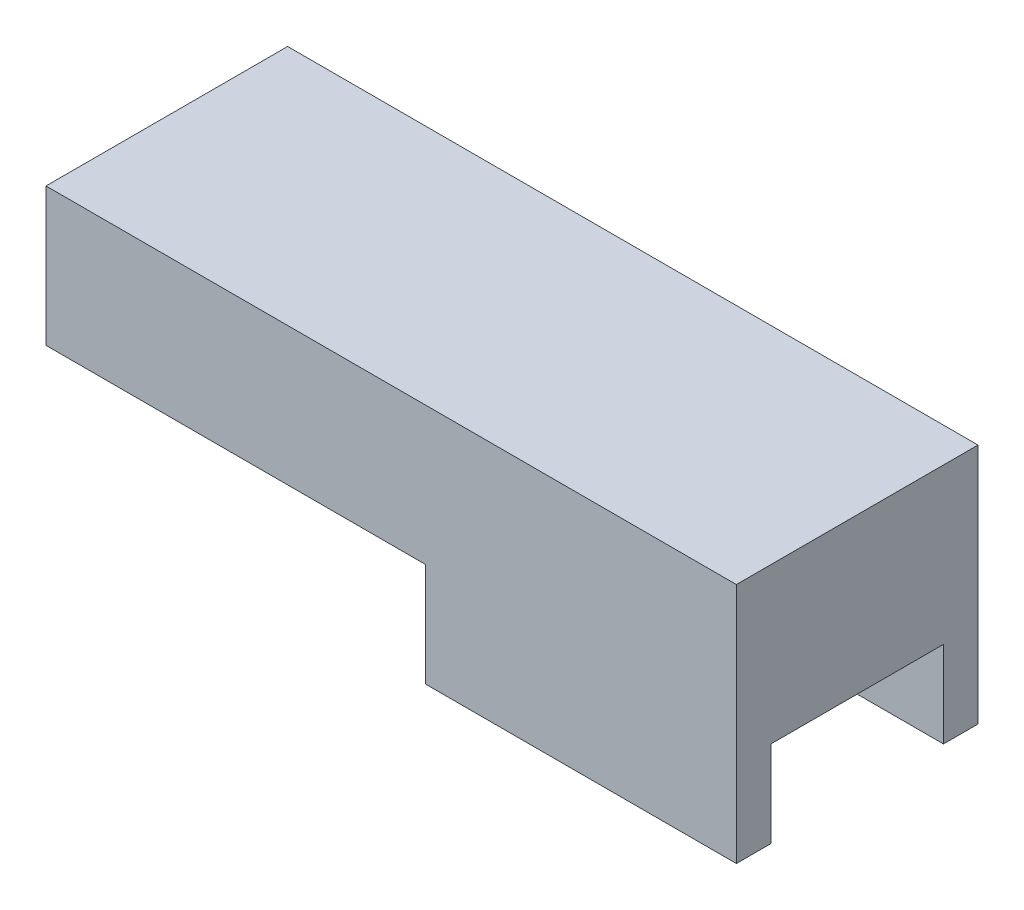
from build123d import *

# Parameters (mm, degrees)
EXTRUDE_2_DEPTH     = 70
SKETCH_3_W          = 50
SKETCH_3_H          = 25
CUT_EXTRUDE_3_DEPTH = 91


with BuildPart() as part:
    # 草图1 → 凸台-拉伸2 (new body)
    with BuildSketch(Plane.XY):
        Polygon((-42.561983471, 30.9508549), (157.438016529, 30.9508549), (157.438016529, -39.0491451), (67.438016529, -39.0491451), (67.438016529, -9.0491451), (-42.561983471, -9.0491451), align=None)
    extrude(amount=EXTRUDE_2_DEPTH)

    # 草图3 → 切除-拉伸3 (cut, through all)
    with BuildSketch(Plane.ZY.offset(-67.438016529)):
        with Locations((35, -26.5491451)):
            Rectangle(SKETCH_3_W, SKETCH_3_H)
    extrude(amount=-CUT_EXTRUDE_3_DEPTH, mode=Mode.SUBTRACT)


solid = part.part
